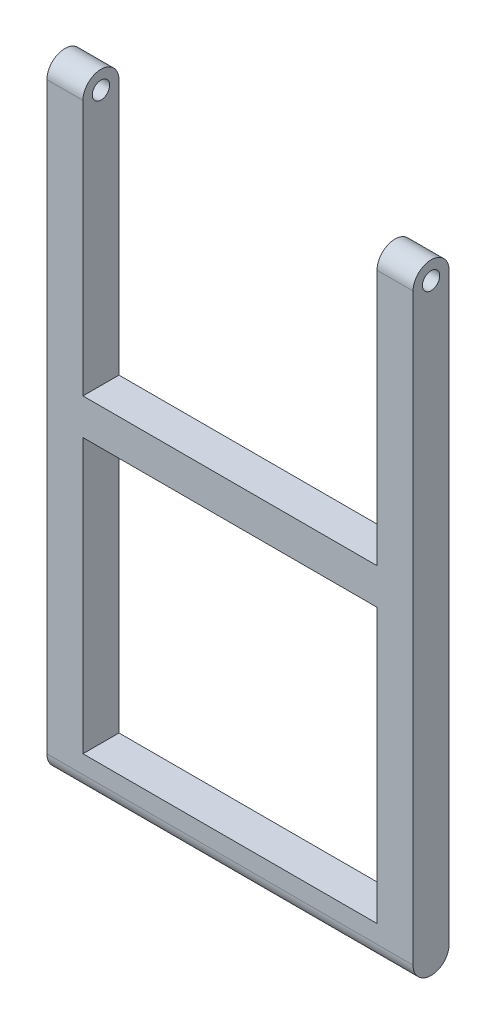
from build123d import *

# Parameters (mm, degrees)
SKICA1_W                 = 40.8
SKICA1_H                 = 38
P_IDAT_VYSUNUT_M1_DEPTH  = 5
SKICA2_R                 = 1.2
ODEBRAT_VYSUNUT_M1_DEPTH = 51.8
ODEBRAT_VYSUNUT_M2_DEPTH = 51.8


with BuildPart() as part:
    # Skica1 → Přidat vysunutím1 (new body)
    with BuildSketch(Plane.XY):
        Polygon((0, 86), (0, 0), (50.8, 0), (50.8, 86), (45.8, 86), (45.8, 48), (5, 48), (5, 86), align=None)
        with Locations((25.4, 24)):
            Rectangle(SKICA1_W, SKICA1_H, mode=Mode.SUBTRACT)
    extrude(amount=P_IDAT_VYSUNUT_M1_DEPTH)

    # Skica2 → Odebrat vysunutím1 (cut, through all)
    with BuildSketch(Plane(origin=(50.8, 0, 0), x_dir=(0, 0, -1), z_dir=(1, 0, 0))):
        with BuildLine():
            Line((-5, 86), (-5, 83.5))
            ThreePointArc((-5, 83.5), (-4.267766969, 85.267766937), (-2.500000046, 86))
            Line((-2.500000046, 86), (-5, 86))
        make_face()
        with BuildLine():
            Line((0, 86), (-2.500000046, 86))
            ThreePointArc((-2.500000046, 86), (-0.732233063, 85.267766969), (0, 83.5))
            Line((0, 83.5), (0, 86))
        make_face()
        with Locations((-2.5, 83.5)):
            Circle(SKICA2_R)
    extrude(amount=-ODEBRAT_VYSUNUT_M1_DEPTH, mode=Mode.SUBTRACT)

    # Skica3 → Odebrat vysunutím2 (cut, through all)
    with BuildSketch(Plane(origin=(50.8, 0, 0), x_dir=(0, 0, -1), z_dir=(1, 0, 0))):
        with BuildLine():
            ThreePointArc((-2.5, 0), (-4.267766953, 0.732233047), (-5, 2.5))
            Line((-5, 2.5), (-5, 0))
            Line((-5, 0), (-2.5, 0))
        make_face()
        with BuildLine():
            ThreePointArc((0, 2.5), (-0.732233047, 0.732233047), (-2.5, 0))
            Line((-2.5, 0), (0, 0))
            Line((0, 0), (0, 2.5))
        make_face()
    extrude(amount=-ODEBRAT_VYSUNUT_M2_DEPTH, mode=Mode.SUBTRACT)


solid = part.part
